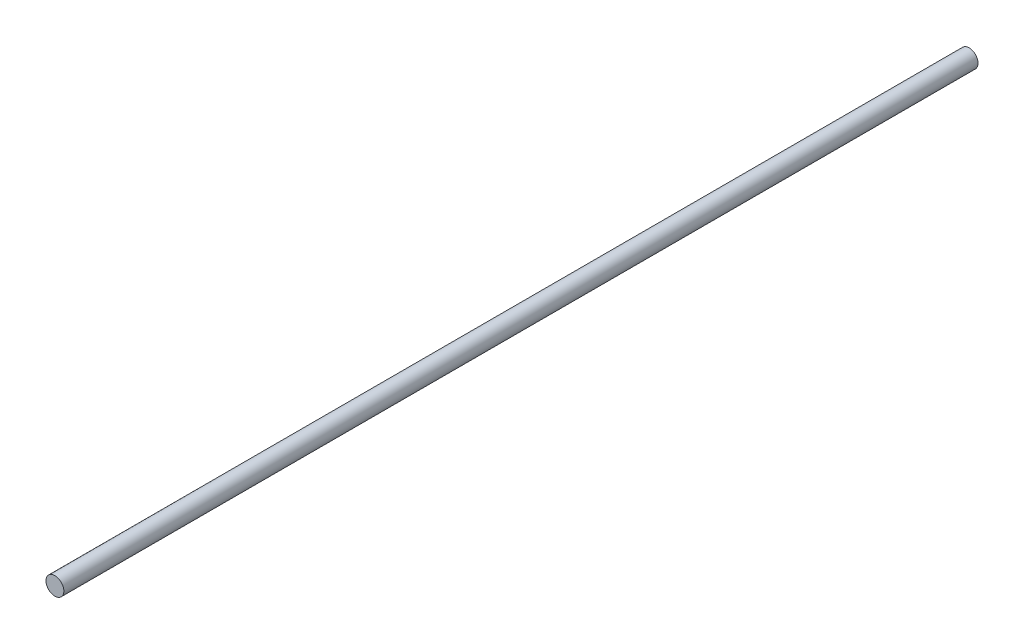
from build123d import *

# Parameters (mm, degrees)
SKETCH1_R           = 4
BOSS_EXTRUDE1_DEPTH = 205


with BuildPart() as part:
    # Sketch1 → Boss-Extrude1 (new body, symmetric)
    with BuildSketch(Plane.XY):
        Circle(SKETCH1_R)
    extrude(amount=BOSS_EXTRUDE1_DEPTH, both=True)


solid = part.part
